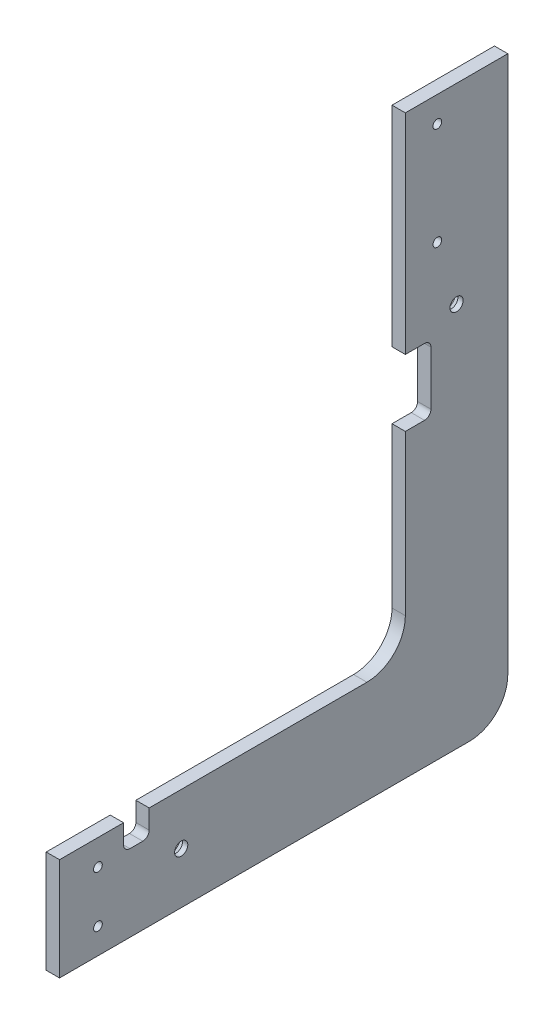
from build123d import *

# Parameters (mm, degrees)
BOSS_EXTRUDE2_DEPTH                               = 6.604
CSK_FOR_8_FLAT_HEAD_SOCKET_CAP_SCREW1_D           = 4.3053
CSK_FOR_8_FLAT_HEAD_SOCKET_CAP_SCREW1_CSINK_D     = 9.1186
CSK_FOR_8_FLAT_HEAD_SOCKET_CAP_SCREW1_CSINK_ANGLE = 82
CSK_FOR_8_FLAT_HEAD_SOCKET_CAP_SCREW2_D           = 4.3053
CSK_FOR_8_FLAT_HEAD_SOCKET_CAP_SCREW2_CSINK_D     = 9.1186
CSK_FOR_8_FLAT_HEAD_SOCKET_CAP_SCREW2_CSINK_ANGLE = 82
CSK_FOR_1_4_FLAT_HEAD_SOCKET_CAP_SCR_2_COUNT      = 2
CSK_FOR_1_4_FLAT_HEAD_SOCKET_CAP_SCR_2_PITCH      = 214.529804424
CUT_EXTRUDE1_DEPTH                                = 7.604


with BuildPart() as part:
    # Sketch1 → Boss-Extrude2 (new body)
    with BuildSketch(Plane(origin=(0, 0, 0), x_dir=(0, 0, -1), z_dir=(1, 0, 0))):
        with BuildLine():
            Line((0, -234.95), (0, -285.75))
            Line((0, -285.75), (203.2, -285.75))
            ThreePointArc((203.2, -285.75), (216.670384182, -280.170384182), (222.25, -266.7))
            Line((222.25, -266.7), (222.25, 0))
            Line((222.25, 0), (171.45, 0))
            Line((171.45, 0), (171.45, -215.9))
            ThreePointArc((171.45, -215.9), (165.870384182, -229.370384182), (152.4, -234.95))
            Line((152.4, -234.95), (0, -234.95))
        make_face()
    extrude(amount=BOSS_EXTRUDE2_DEPTH)

    # CSK for #8 Flat Head Socket Cap Screw1 (through all)
    with Locations(Plane(origin=(0, -130.017092458, -32.785257097), x_dir=(0, 0, 1), z_dir=(-1, 0, 0))):
        with Locations((-154.539742903, 117.317092458), (-154.539742903, 66.517092458)):
            CounterSinkHole(CSK_FOR_8_FLAT_HEAD_SOCKET_CAP_SCREW1_D / 2, CSK_FOR_8_FLAT_HEAD_SOCKET_CAP_SCREW1_CSINK_D / 2, counter_sink_angle=CSK_FOR_8_FLAT_HEAD_SOCKET_CAP_SCREW1_CSINK_ANGLE)

    # CSK for #8 Flat Head Socket Cap Screw2 (through all)
    with Locations(Plane(origin=(0, 131.594255301, -188.074513541), x_dir=(0, 0, 1), z_dir=(-1, 0, 0))):
        with Locations((169.024513541, -379.244255301), (169.024513541, -404.644255301)):
            CounterSinkHole(CSK_FOR_8_FLAT_HEAD_SOCKET_CAP_SCREW2_D / 2, CSK_FOR_8_FLAT_HEAD_SOCKET_CAP_SCREW2_CSINK_D / 2, counter_sink_angle=CSK_FOR_8_FLAT_HEAD_SOCKET_CAP_SCREW2_CSINK_ANGLE)

    # Sketch9 → CSK for 1/4 Flat Head Socket Cap Screw1 (revolve, cut)
    with BuildSketch(Plane(origin=(0, -94.869, -196.85), x_dir=(0, 0, 1), z_dir=(0, 1, 0))):
        Polygon((0, 0), (0, 6.604), (3.2639, 6.604), (3.2639, 4.003051983), (6.7437, 0), align=None)
    csk_for_1_4_flat_head_socket_cap_screw1 = revolve(axis=Axis((-6.35, -94.869, -196.85), (1, 0, 0)), mode=Mode.SUBTRACT)

    # CSK for 1_4 Flat Head Socket Cap Scr 2: CSK for 1/4 Flat Head Socket Cap Screw1 ×2
    with Locations(*[Vector(0, -0.771366013, 0.636391761) * (i * CSK_FOR_1_4_FLAT_HEAD_SOCKET_CAP_SCR_2_PITCH) for i in range(1, CSK_FOR_1_4_FLAT_HEAD_SOCKET_CAP_SCR_2_COUNT)]):
        add(csk_for_1_4_flat_head_socket_cap_screw1, mode=Mode.SUBTRACT)

    # Sketch11 → Cut-Extrude1 (cut, through all)
    with BuildSketch(Plane.ZY):
        with BuildLine():
            Line((-171.45, -103.759), (-180.975, -103.759))
            ThreePointArc((-180.975, -103.759), (-183.22006403, -104.68893597), (-184.15, -106.934))
            Line((-184.15, -106.934), (-184.15, -133.604))
            ThreePointArc((-184.15, -133.604), (-183.22006403, -135.84906403), (-180.975, -136.779))
            Line((-180.975, -136.779), (-171.45, -136.779))
            Line((-171.45, -136.779), (-171.45, -103.759))
        make_face()
        with BuildLine():
            Line((-44.45, -234.95), (-31.75, -234.95))
            Line((-31.75, -234.95), (-31.75, -244.475))
            ThreePointArc((-31.75, -244.475), (-32.67993597, -246.72006403), (-34.925, -247.65))
            Line((-34.925, -247.65), (-41.275, -247.65))
            ThreePointArc((-41.275, -247.65), (-43.52006403, -246.72006403), (-44.45, -244.475))
            Line((-44.45, -244.475), (-44.45, -234.95))
        make_face()
    extrude(amount=-CUT_EXTRUDE1_DEPTH, mode=Mode.SUBTRACT)


solid = part.part
